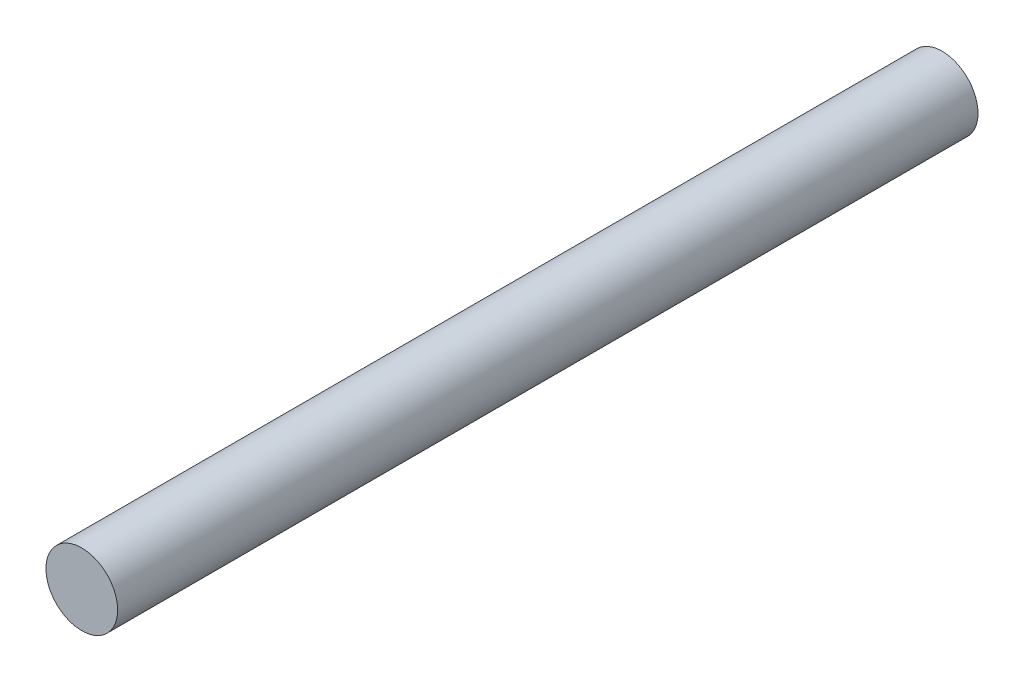
from build123d import *

# Parameters (mm, degrees)
SKETCH1_R           = 3.75
BOSS_EXTRUDE1_DEPTH = 90


with BuildPart() as part:
    # Sketch1 → Boss-Extrude1 (new body)
    with BuildSketch(Plane.XY):
        Circle(SKETCH1_R)
    extrude(amount=BOSS_EXTRUDE1_DEPTH)


solid = part.part
